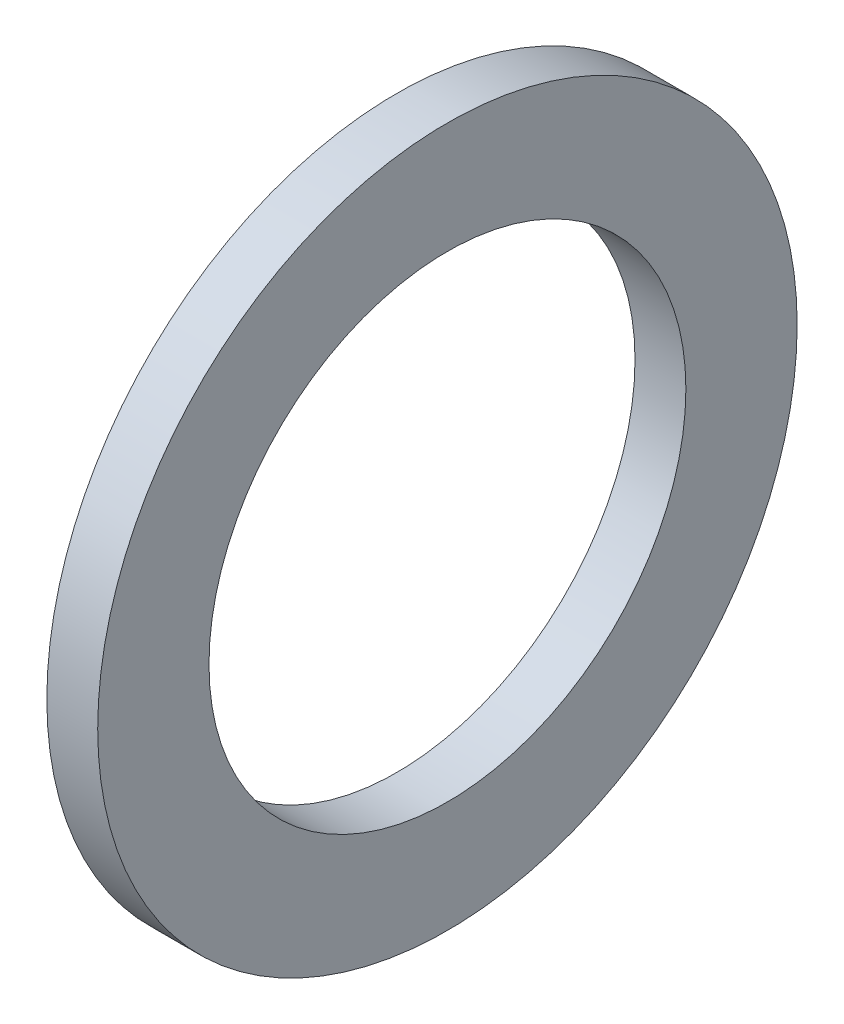
from build123d import *

# Parameters (mm, degrees)
SKETCH1_R           = 11
SKETCH1_R_2         = 7.5
BOSS_EXTRUDE1_DEPTH = 1.6


with BuildPart() as part:
    # Sketch1 → Boss-Extrude1 (new body)
    with BuildSketch(Plane(origin=(0, 0, 0), x_dir=(0, 0, -1), z_dir=(1, 0, 0))):
        Circle(SKETCH1_R)
        Circle(SKETCH1_R_2, mode=Mode.SUBTRACT)
    extrude(amount=BOSS_EXTRUDE1_DEPTH)


solid = part.part
